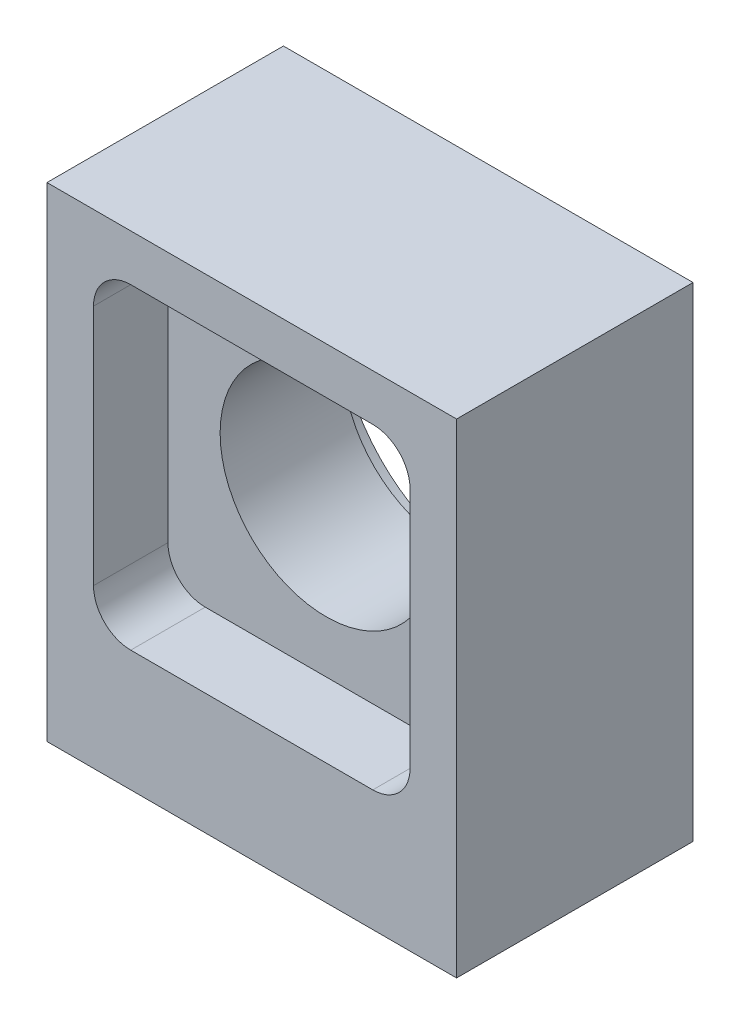
from build123d import *

# Parameters (mm, degrees)
SKETCH1_W                       = 22
SKETCH1_H                       = 12.7
BOSS_EXTRUDE1_DEPTH             = 26
M3X0_5_TAPPED_HOLE2_D           = 2.5
M3X0_5_TAPPED_HOLE2_DEPTH       = 5
M3X0_5_TAPPED_HOLE2_CSINK_D     = 3.05
M3X0_5_TAPPED_HOLE2_CSINK_ANGLE = 90
M3X0_5_TAPPED_HOLE2_TIP         = 0.751075774
SKETCH7_R                       = 5.7
CUT_EXTRUDE1_DEPTH              = 13.7
SKETCH8_W                       = 17
SKETCH8_H                       = 17
CUT_EXTRUDE2_DEPTH              = 4
FILLET1_R                       = 2
SKETCH9_R                       = 8.05
CUT_EXTRUDE3_DEPTH              = 2.1


with BuildPart() as part:
    # Sketch1 → Boss-Extrude1 (new body)
    with BuildSketch(Plane(origin=(0, 0, 0), x_dir=(1, 0, 0), z_dir=(0, 1, 0))):
        with Locations((11, 6.35)):
            Rectangle(SKETCH1_W, SKETCH1_H)
    extrude(amount=BOSS_EXTRUDE1_DEPTH)

    # Sketch2 → M3x0.5 Tapped Hole1 (revolve, cut)
    with BuildSketch(Plane(origin=(18, 0, -3), x_dir=(0, 0, -1), z_dir=(1, 0, 0))):
        Polygon((0, 0), (0, 5.751075774), (1.25, 5), (1.25, 0.275), (1.525, 0), align=None)
    m3x0_5_tapped_hole1 = revolve(axis=Axis((18, -6.35, -3), (0, 1, 0)), mode=Mode.SUBTRACT)

    # Mirror1: M3x0.5 Tapped Hole1 across plane
    add(m3x0_5_tapped_hole1.mirror(Plane.XY.offset(-6.35)), mode=Mode.SUBTRACT)

    # Mirror2: M3x0.5 Tapped Hole1 across plane
    add(m3x0_5_tapped_hole1.mirror(Plane(origin=(11, 0, 0), x_dir=(0, 0, 1), z_dir=(1, 0, 0))), mode=Mode.SUBTRACT)

    # Mirror2 copy 1 sketch → Mirror2 copy 1 (revolve, cut)
    with BuildSketch(Plane(origin=(4, 0, -9.7), x_dir=(0, 0, 1), z_dir=(-1, 0, 0))):
        Polygon((0, 0), (0, 5.751075774), (1.25, 5), (1.25, 0.275), (1.525, 0), align=None)
    revolve(axis=Axis((4, -6.35, -9.7), (0, 1, 0)), mode=Mode.SUBTRACT)

    # M3x0.5 Tapped Hole2
    with Locations(Plane(origin=(0, 0, 0), x_dir=(-1, 0, 0), z_dir=(0, -1, 0))):
        with Locations((-11, 6.35)):
            CounterSinkHole(M3X0_5_TAPPED_HOLE2_D / 2, M3X0_5_TAPPED_HOLE2_CSINK_D / 2, depth=M3X0_5_TAPPED_HOLE2_DEPTH, counter_sink_angle=M3X0_5_TAPPED_HOLE2_CSINK_ANGLE)
            with Locations((0, 0, -(M3X0_5_TAPPED_HOLE2_DEPTH + M3X0_5_TAPPED_HOLE2_TIP / 2))):  # 118° drill point
                Cone(0, M3X0_5_TAPPED_HOLE2_D / 2, M3X0_5_TAPPED_HOLE2_TIP, mode=Mode.SUBTRACT)

    # Sketch7 → Cut-Extrude1 (cut, through all)
    with BuildSketch(Plane.XY):
        with Locations((11, 15)):
            Circle(SKETCH7_R)
    extrude(amount=-CUT_EXTRUDE1_DEPTH, mode=Mode.SUBTRACT)

    # Sketch8 → Cut-Extrude2 (cut)
    with BuildSketch(Plane.XY):
        with Locations((11, 15)):
            Rectangle(SKETCH8_W, SKETCH8_H)
    extrude(amount=-CUT_EXTRUDE2_DEPTH, mode=Mode.SUBTRACT)

    # Fillet1
    fillet1_edges = [part.edges().sort_by_distance(p)[0] for p in [
        (2.5, 6.5, -2),
        (2.5, 23.5, -2),
        (19.5, 23.5, -2),
        (19.5, 6.5, -2),
    ]]
    fillet(fillet1_edges, radius=FILLET1_R)

    # Sketch9 → Cut-Extrude3 (cut)
    with BuildSketch(Plane(origin=(0, 0, -12.7), x_dir=(-1, 0, 0), z_dir=(0, 0, -1))):
        with Locations((-11, 15)):
            Circle(SKETCH9_R)
    extrude(amount=-CUT_EXTRUDE3_DEPTH, mode=Mode.SUBTRACT)


solid = part.part
